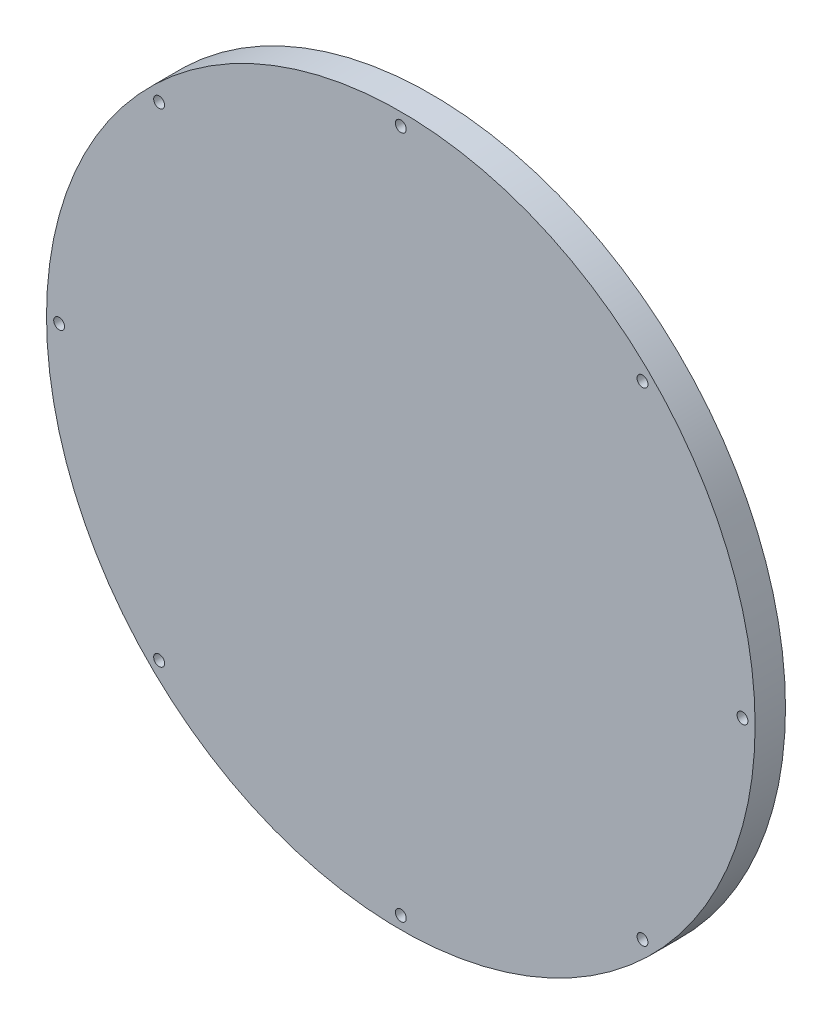
from build123d import *

# Parameters (mm, degrees)
SKETCH1_R                                       = 140
BOSS_EXTRUDE1_DEPTH                             = 12
CSK_FOR_M4_FLAT_HEAD_MACHINE_SCREW1_D           = 4.3
CSK_FOR_M4_FLAT_HEAD_MACHINE_SCREW1_CSINK_D     = 9.4
CSK_FOR_M4_FLAT_HEAD_MACHINE_SCREW1_CSINK_ANGLE = 90


with BuildPart() as part:
    # Sketch1 → Boss-Extrude1 (new body)
    with BuildSketch(Plane.XY):
        Circle(SKETCH1_R)
    extrude(amount=BOSS_EXTRUDE1_DEPTH)

    # CSK for M4 Flat Head Machine Screw1 (through all)
    with Locations(Plane(origin=(0, 0, 0), x_dir=(-1, 0, 0), z_dir=(0, 0, -1))):
        with Locations((0, 135), (135, 0), (0, -135), (-135, 0), (-95.5, 95.5), (95.5, 95.5), (95.5, -95.5), (-95.5, -95.5)):
            CounterSinkHole(CSK_FOR_M4_FLAT_HEAD_MACHINE_SCREW1_D / 2, CSK_FOR_M4_FLAT_HEAD_MACHINE_SCREW1_CSINK_D / 2, counter_sink_angle=CSK_FOR_M4_FLAT_HEAD_MACHINE_SCREW1_CSINK_ANGLE)


solid = part.part
